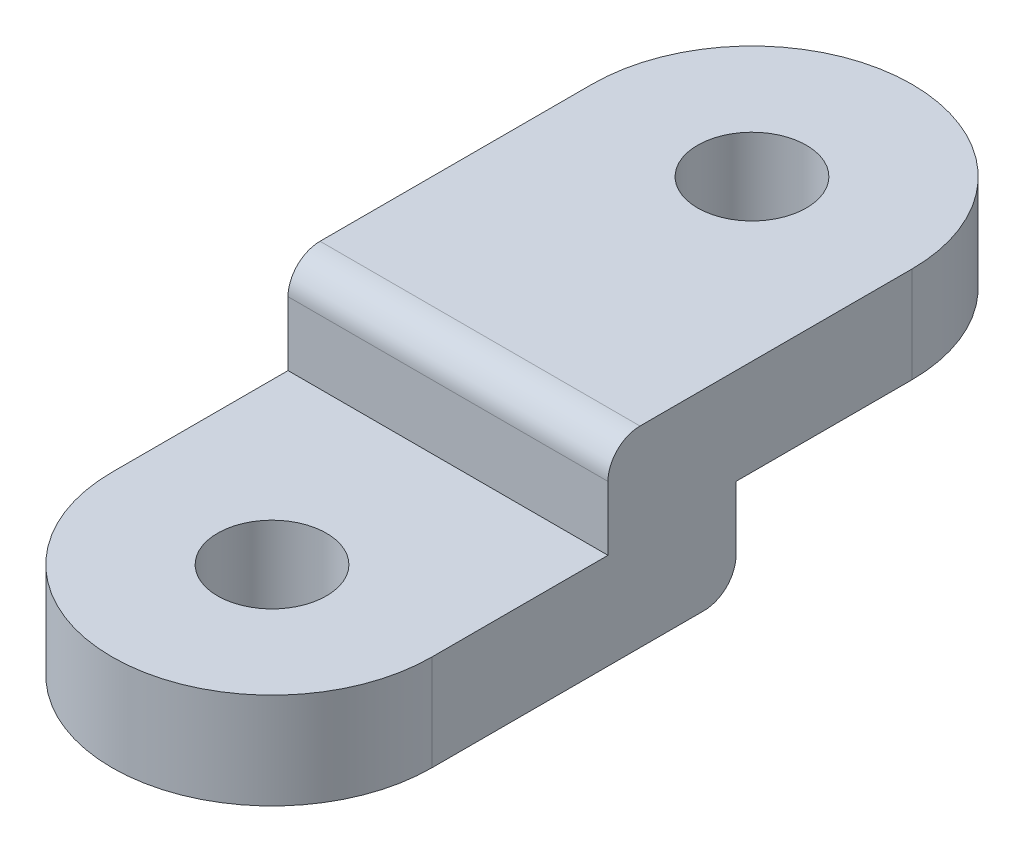
from build123d import *

# Parameters (mm, degrees)
BOSS_EXTRU_1_DEPTH      = 6
BOSS_EXTRU_2_DEPTH      = 12
ESQUISSE14_W            = 21
ESQUISSE14_H            = 6
ENL_V_MAT_EXTRU_2_DEPTH = 21
TROU_TARAUD_M81_D       = 6.8
TROU_TARAUD_M82_D       = 6.8
CONG_1_R                = 2


with BuildPart() as part:
    # Esquisse1 → Boss.-Extru.1 (new body)
    with BuildSketch(Plane(origin=(0, 0, 0), x_dir=(1, 0, 0), z_dir=(0, 1, 0))):
        with BuildLine():
            Line((0, 0), (0, 30))
            ThreePointArc((0, 30), (10, 40), (20, 30))
            Line((20, 30), (20, 0))
            ThreePointArc((20, 0), (10, -10), (0, 0))
        make_face()
    extrude(amount=BOSS_EXTRU_1_DEPTH)

    # Esquisse12 → Boss.-Extru.2 (add)
    with BuildSketch(Plane.XZ):
        with BuildLine():
            Line((0, -30), (20, -30))
            Line((20, -30), (20, 0))
            ThreePointArc((20, 0), (10, 10), (0, 0))
            Line((0, 0), (0, -30))
        make_face()
    extrude(amount=BOSS_EXTRU_2_DEPTH)

    # Esquisse14 → Enlèv. mat.-Extru.2 (cut, through all)
    with BuildSketch(Plane(origin=(20, 0, 0), x_dir=(0, 0, -1), z_dir=(1, 0, 0))):
        with Locations((0.5, 3)):
            Rectangle(ESQUISSE14_W, ESQUISSE14_H)
        Polygon((30, 0), (19, 0), (19, -6), (-10, -6), (-10, -12), (30, -12), align=None)
    extrude(amount=-ENL_V_MAT_EXTRU_2_DEPTH, mode=Mode.SUBTRACT)

    # Trou taraudé M81 (through all)
    with Locations(Plane(origin=(0, 6, 0), x_dir=(1, 0, 0), z_dir=(0, 1, 0))):
        with Locations((10, 30)):
            Hole(TROU_TARAUD_M81_D / 2)

    # Trou taraudé M82 (through all)
    with Locations(Plane(origin=(0, 0, 0), x_dir=(1, 0, 0), z_dir=(0, 1, 0))):
        with Locations((10, 0)):
            Hole(TROU_TARAUD_M82_D / 2)

    # Congé1
    cong_1_edges = [part.edges().sort_by_distance(p)[0] for p in [
        (10, -6, -19),
        (10, 6, -11),
    ]]
    fillet(cong_1_edges, radius=CONG_1_R)


solid = part.part
